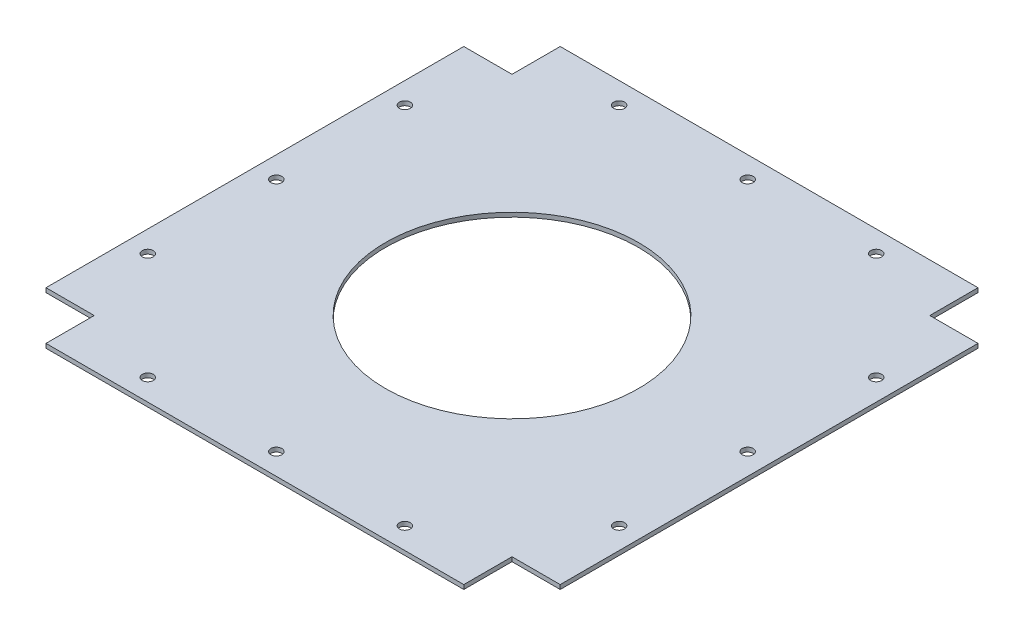
from build123d import *

# Parameters (mm, degrees)
SKETCH1_R           = 3.2385
SKETCH1_R_2         = 75
BOSS_EXTRUDE1_DEPTH = 2.54


with BuildPart() as part:
    # Sketch1 → Boss-Extrude1 (new body)
    with BuildSketch(Plane(origin=(0, 0, 0), x_dir=(1, 0, 0), z_dir=(0, 1, 0))):
        Polygon((123.825, 152.4), (123.825, 123.825), (152.4, 123.825), (152.4, -123.825), (123.825, -123.825), (123.825, -152.4), (-123.825, -152.4), (-123.825, -123.825), (-152.4, -123.825), (-152.4, 123.825), (-123.825, 123.825), (-123.825, 152.4), align=None)
        with Locations((76.2, 139.7)):
            Circle(SKETCH1_R, mode=Mode.SUBTRACT)
        with Locations((0, 139.7)):
            Circle(SKETCH1_R, mode=Mode.SUBTRACT)
        with Locations((-76.2, 139.7)):
            Circle(SKETCH1_R, mode=Mode.SUBTRACT)
        with Locations((-76.2, -139.7)):
            Circle(SKETCH1_R, mode=Mode.SUBTRACT)
        with Locations((0, -139.7)):
            Circle(SKETCH1_R, mode=Mode.SUBTRACT)
        with Locations((76.2, -139.7)):
            Circle(SKETCH1_R, mode=Mode.SUBTRACT)
        with Locations((139.7, -76.2)):
            Circle(SKETCH1_R, mode=Mode.SUBTRACT)
        with Locations((139.7, 0)):
            Circle(SKETCH1_R, mode=Mode.SUBTRACT)
        with Locations((139.7, 76.2)):
            Circle(SKETCH1_R, mode=Mode.SUBTRACT)
        with Locations((-139.7, 76.2)):
            Circle(SKETCH1_R, mode=Mode.SUBTRACT)
        with Locations((-139.7, 0)):
            Circle(SKETCH1_R, mode=Mode.SUBTRACT)
        with Locations((-139.7, -76.2)):
            Circle(SKETCH1_R, mode=Mode.SUBTRACT)
        Circle(SKETCH1_R_2, mode=Mode.SUBTRACT)
    extrude(amount=BOSS_EXTRUDE1_DEPTH)


solid = part.part
